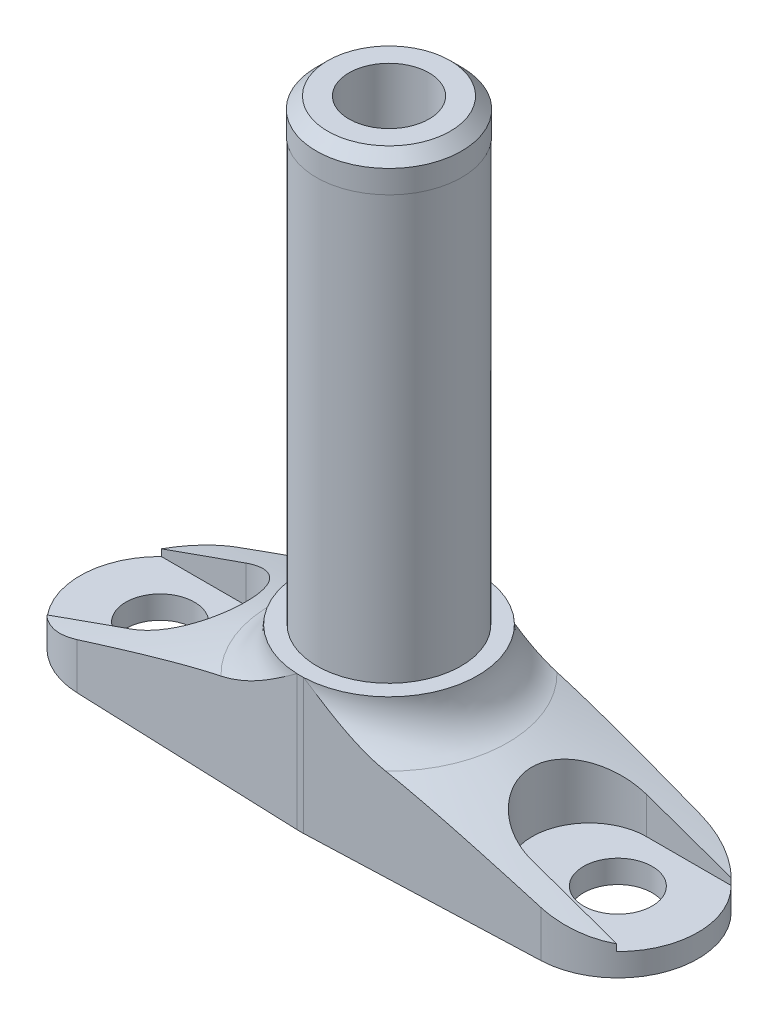
from build123d import *

# Parameters (mm, degrees)
SZKIC1_W                        = 27
SZKIC1_H                        = 25
ZAOKR_GLENIE1_R                 = 4
SZKIC4_R                        = 3
WYTNIJ_WYCI_GNI_CIE3_DEPTH      = 24.0000001
WYTNIJ_WYCI_GNI_CIE3_DEPTH_BACK = 3
WYTNIJ_WYCI_GNI_CIE2_DEPTH      = 24.0000001
SZKIC5_OUTSIDE_W                = 72.072
SZKIC5_OUTSIDE_H                = 72.072
WYTNIJ_WYCI_GNI_CIE4_DEPTH      = 26.0000001
SZKIC8_W                        = 7.75
SZKIC8_H                        = 13.192742838
SZKIC10_R                       = 3.5
WYTNIJ_WYCI_GNI_CIE5_DEPTH      = 52.807257262


with BuildPart() as part:
    # Szkic1 → Obrót1 (revolve)
    with BuildSketch(Plane.XY):
        with Locations((13.5, 12.5)):
            Rectangle(SZKIC1_W, SZKIC1_H)
    revolve(axis=Axis((0, 0, 0), (0, 1, 0)))

    # Szkic2 → Wycięcie-obrót1 (revolve, cut)
    with BuildSketch(Plane.XY):
        Polygon((27, 25), (27, 2), (7.75, 9.00642701), (7.75, 25), align=None)
    revolve(axis=Axis((0, 0, 0), (0, 1, 0)), mode=Mode.SUBTRACT)

    # Zaokrąglenie1
    zaokr_glenie1_edges = [part.edges().sort_by_distance(p)[0] for p in [
        (-7.75, 9.00642701, 0),
    ]]
    fillet(zaokr_glenie1_edges, radius=ZAOKR_GLENIE1_R)

    # Szkic4 → Wytnij-wyciągnięcie3 (cut, two sides)
    with BuildSketch(Plane(origin=(0, 2, 0), x_dir=(1, 0, 0), z_dir=(0, 1, 0))) as wytnij_wyci_gni_cie3_sk:
        with Locations((-20, 0)):
            Circle(SZKIC4_R)
        with Locations((20, 0)):
            Circle(SZKIC4_R)
    extrude(amount=WYTNIJ_WYCI_GNI_CIE3_DEPTH, mode=Mode.SUBTRACT)
    extrude(wytnij_wyci_gni_cie3_sk.sketch, amount=-WYTNIJ_WYCI_GNI_CIE3_DEPTH_BACK, mode=Mode.SUBTRACT)

    # Szkic3 → Wytnij-wyciągnięcie2 (cut, through all)
    with BuildSketch(Plane(origin=(0, 2, 0), x_dir=(1, 0, 0), z_dir=(0, 1, 0))):
        with BuildLine():
            Line((-17.5, 5), (-26.532998323, 5))
            ThreePointArc((-26.532998323, 5), (-27, 0), (-26.532998323, -5))
            Line((-26.532998323, -5), (-17.5, -5))
            ThreePointArc((-17.5, -5), (-12.5, 0), (-17.5, 5))
        make_face()
        with BuildLine():
            Line((17.5, 5), (26.532998323, 5))
            ThreePointArc((26.532998323, 5), (27, 0), (26.532998323, -5))
            Line((26.532998323, -5), (17.5, -5))
            ThreePointArc((17.5, -5), (12.5, 0), (17.5, 5))
        make_face()
    extrude(amount=WYTNIJ_WYCI_GNI_CIE2_DEPTH, mode=Mode.SUBTRACT)

    # Szkic5 outside → Wytnij-wyciągnięcie4 (cut, through all)
    with BuildSketch(Plane.XZ):
        Rectangle(SZKIC5_OUTSIDE_W, SZKIC5_OUTSIDE_H)
        with BuildLine():
            Line((-20.2625, 6.995076393), (-0.290625, 7.744548864))
            ThreePointArc((-0.290625, 7.744548864), (0, 7.75), (0.290625, 7.744548864))
            Line((0.290625, 7.744548864), (20.2625, 6.995076393))
            ThreePointArc((20.2625, 6.995076393), (27, 0), (20.2625, -6.995076393))
            Line((20.2625, -6.995076393), (0.290625, -7.744548864))
            ThreePointArc((0.290625, -7.744548864), (0, -7.75), (-0.290625, -7.744548864))
            Line((-0.290625, -7.744548864), (-20.2625, -6.995076393))
            ThreePointArc((-20.2625, -6.995076393), (-27, 0), (-20.2625, 6.995076393))
        make_face(mode=Mode.SUBTRACT)
    extrude(amount=-WYTNIJ_WYCI_GNI_CIE4_DEPTH, mode=Mode.SUBTRACT)

    # Szkic8 → Wycięcie-obrót2 (revolve, cut)
    with BuildSketch(Plane.XY):
        with Locations((3.875, 18.403628581)):
            Rectangle(SZKIC8_W, SZKIC8_H)
    revolve(axis=Axis((0, 25, 0), (0, -1, 0)), mode=Mode.SUBTRACT)

    # Szkic9 → Obrót2 (revolve)
    with BuildSketch(Plane.XY):
        Polygon((5.35, 51.807257162), (0, 51.807257162), (0, 11.807257162), (6.3, 11.807257162), (6.3, 48.807257162), (6.35, 48.807257162), (6.35, 50.807257162), align=None)
    revolve(axis=Axis((0, 11.807257162, 0), (0, 1, 0)))

    # Szkic10 → Wytnij-wyciągnięcie5 (cut, through all)
    with BuildSketch(Plane(origin=(0, 51.807257162, 0), x_dir=(1, 0, 0), z_dir=(0, 1, 0))):
        Circle(SZKIC10_R)
    extrude(amount=-WYTNIJ_WYCI_GNI_CIE5_DEPTH, mode=Mode.SUBTRACT)


solid = part.part
